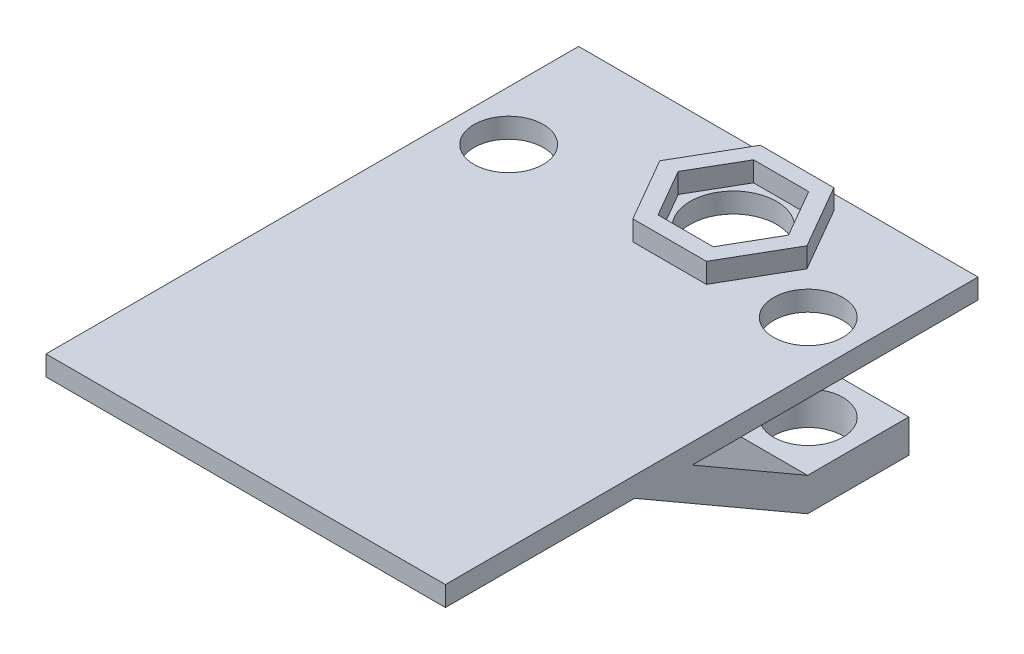
from build123d import *

# Parameters (mm, degrees)
SKETCH1_W               = 60
SKETCH1_H               = 80
SKETCH1_R               = 6.5
BOSS_EXTRUDE4_DEPTH     = 3
BOSS_EXTRUDE5_START     = 30
BOSS_EXTRUDE5_DEPTH     = 15
BOSS_EXTRUDE6_START     = -30
BOSS_EXTRUDE6_DEPTH     = 15
BOSS_EXTRUDE7_DEPTH     = 6
SKETCH1_7_R             = 5.2
CUT_EXTRUDE1_DEPTH      = 7
CUT_EXTRUDE1_DEPTH_BACK = 16


with BuildPart() as part:
    # Sketch1 → Boss-Extrude4 (new body)
    with BuildSketch(Plane(origin=(0, 0, 0), x_dir=(1, 0, 0), z_dir=(0, 1, 0))):
        Rectangle(SKETCH1_W, SKETCH1_H)
        with Locations((5.03, 28.22)):
            Circle(SKETCH1_R, mode=Mode.SUBTRACT)
    extrude(amount=BOSS_EXTRUDE4_DEPTH)

    # Sketch2 → Boss-Extrude5 (add)
    with BuildSketch(Plane(origin=(0, 0, 0), x_dir=(0, 0, -1), z_dir=(1, 0, 0)).offset(BOSS_EXTRUDE5_START)):
        Polygon((-2.920508076, 0), (-11.580762114, 0), (14.4, -15), (29.6, -15), (29.6, -10), (14.4, -10), align=None)
    extrude(amount=-BOSS_EXTRUDE5_DEPTH)

    # Sketch2_3 → Boss-Extrude6 (add)
    with BuildSketch(Plane(origin=(0, 0, 0), x_dir=(0, 0, -1), z_dir=(1, 0, 0)).offset(BOSS_EXTRUDE6_START)):
        Polygon((-2.920508076, 0), (-11.580762114, 0), (14.4, -15), (29.6, -15), (29.6, -10), (14.4, -10), align=None)
    extrude(amount=BOSS_EXTRUDE6_DEPTH)

    # Sketch1_6 → Boss-Extrude7 (add)
    with BuildSketch(Plane(origin=(0, 0, 0), x_dir=(1, 0, 0), z_dir=(0, 1, 0))):
        Polygon((-6.026257655, 28.22), (-0.498128827, 18.645), (10.558128827, 18.645), (16.086257655, 28.22), (10.558128827, 37.795), (-0.498128827, 37.795), align=None)
        Polygon((9.172488181, 35.395), (0.887511819, 35.395), (-3.254976363, 28.22), (0.887511819, 21.045), (9.172488181, 21.045), (13.314976363, 28.22), align=None, mode=Mode.SUBTRACT)
    extrude(amount=BOSS_EXTRUDE7_DEPTH)

    # Sketch1_7 → Cut-Extrude1 (cut, two sides)
    with BuildSketch(Plane(origin=(0, 0, 0), x_dir=(1, 0, 0), z_dir=(0, 1, 0))) as cut_extrude1_sk:
        with Locations((-22.5, 22)):
            Circle(SKETCH1_7_R)
        with Locations((22.5, 22)):
            Circle(SKETCH1_7_R)
    extrude(amount=CUT_EXTRUDE1_DEPTH, mode=Mode.SUBTRACT)
    extrude(cut_extrude1_sk.sketch, amount=-CUT_EXTRUDE1_DEPTH_BACK, mode=Mode.SUBTRACT)


solid = part.part
